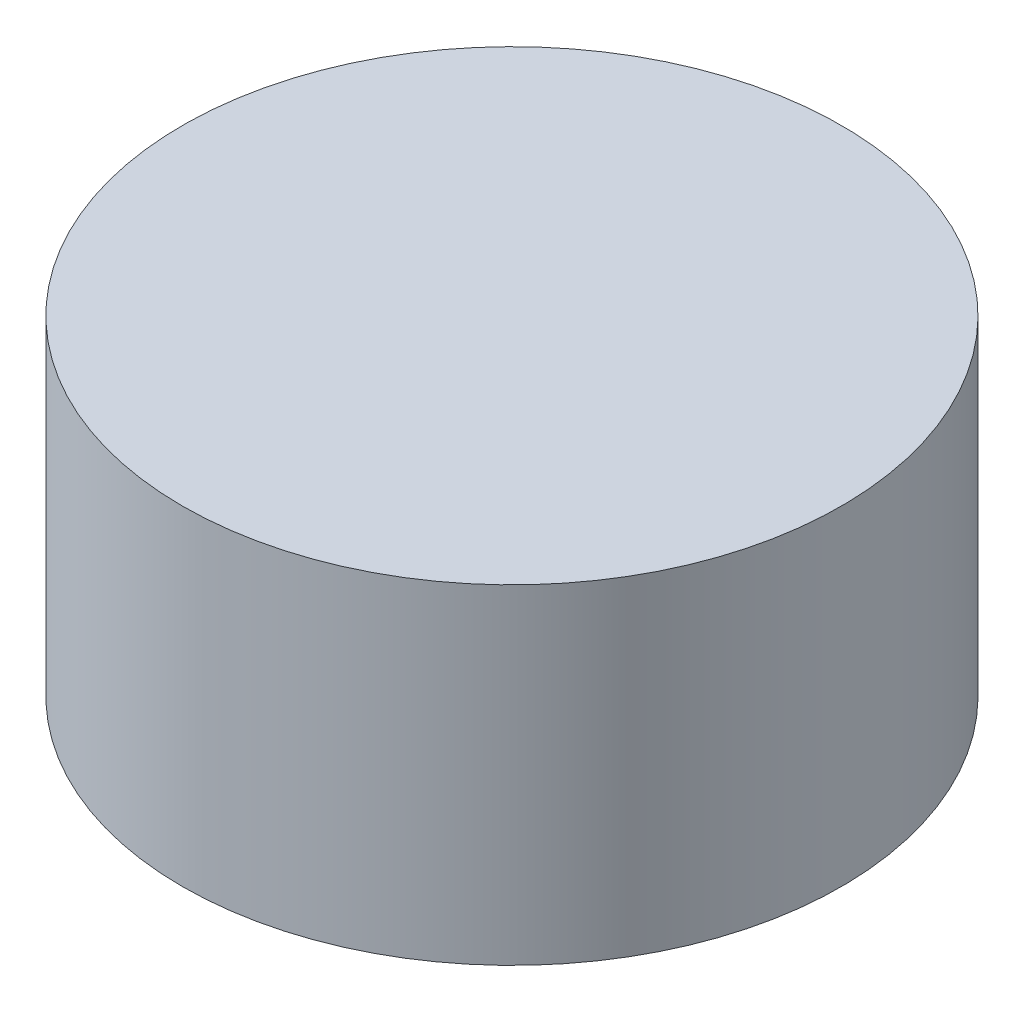
from build123d import *

# Parameters (mm, degrees)
SKETCH1_R           = 2.5
BOSS_EXTRUDE1_DEPTH = 2.5


with BuildPart() as part:
    # Sketch1 → Boss-Extrude1 (new body)
    with BuildSketch(Plane(origin=(0, 0, 0), x_dir=(1, 0, 0), z_dir=(0, 1, 0))):
        with Locations((-23.880911117, 21.852373136)):
            Circle(SKETCH1_R)
    extrude(amount=BOSS_EXTRUDE1_DEPTH)


solid = part.part
